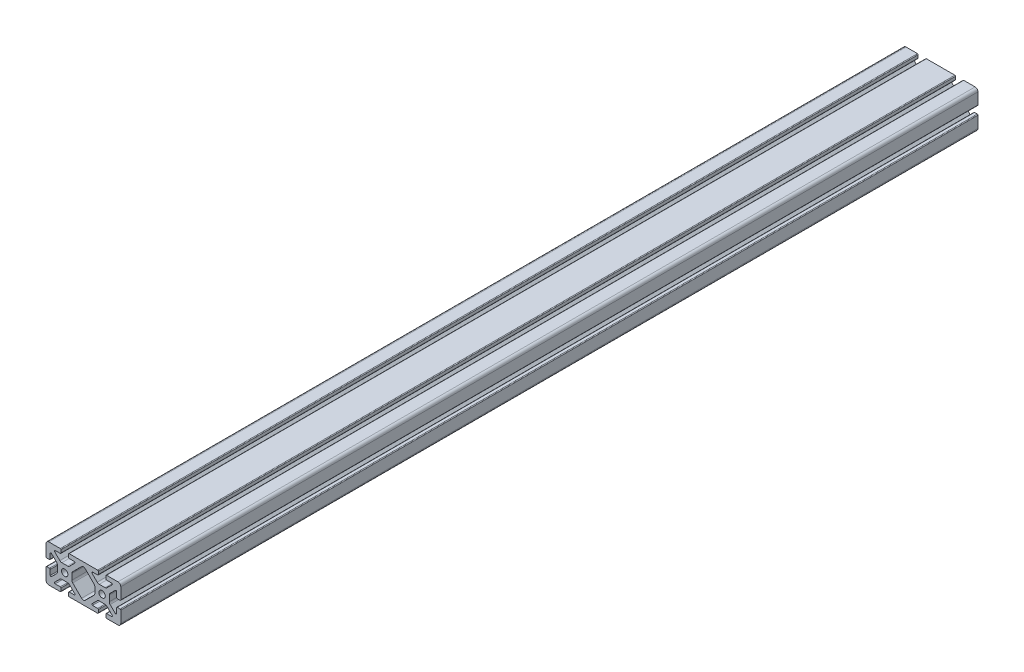
from build123d import *

# Parameters (mm, degrees)
SKETCH1_R           = 3.4036
BOSS_EXTRUDE1_DEPTH = 457.2


with BuildPart() as part:
    # Sketch1 → Boss-Extrude1 (new body, symmetric)
    with BuildSketch(Plane.XY):
        with BuildLine():
            Line((-39.878, 16.891), (-39.878, 4.7625))
            ThreePointArc((-39.878, 4.7625), (-39.654815367, 4.223684633), (-39.116, 4.0005))
            Line((-39.116, 4.0005), (-36.1442, 4.0005))
            ThreePointArc((-36.1442, 4.0005), (-35.605384633, 4.223684633), (-35.3822, 4.7625))
            Line((-35.3822, 4.7625), (-35.3822, 10.2235))
            ThreePointArc((-35.3822, 10.2235), (-34.911804775, 10.927496204), (-34.081384633, 10.762315367))
            Line((-34.081384633, 10.762315367), (-28.513059555, 5.19399029))
            ThreePointArc((-28.513059555, 5.19399029), (-27.863348265, 4.221628629), (-27.6352, 3.074649845))
            Line((-27.6352, 3.074649845), (-27.6352, -3.074649845))
            ThreePointArc((-27.6352, -3.074649845), (-27.863348265, -4.221628629), (-28.513059555, -5.19399029))
            Line((-28.513059555, -5.19399029), (-34.081384633, -10.762315367))
            ThreePointArc((-34.081384633, -10.762315367), (-34.911804775, -10.927496204), (-35.3822, -10.2235))
            Line((-35.3822, -10.2235), (-35.3822, -4.7625))
            ThreePointArc((-35.3822, -4.7625), (-35.605384633, -4.223684633), (-36.1442, -4.0005))
            Line((-36.1442, -4.0005), (-39.116, -4.0005))
            ThreePointArc((-39.116, -4.0005), (-39.654815367, -4.223684633), (-39.878, -4.7625))
            Line((-39.878, -4.7625), (-39.878, -16.891))
            ThreePointArc((-39.878, -16.891), (-38.985261469, -19.046261469), (-36.83, -19.939))
            Line((-36.83, -19.939), (-24.7015, -19.939))
            ThreePointArc((-24.7015, -19.939), (-24.162684633, -19.715815367), (-23.9395, -19.177))
            Line((-23.9395, -19.177), (-23.9395, -16.2052))
            ThreePointArc((-23.9395, -16.2052), (-24.162684633, -15.666384633), (-24.7015, -15.4432))
            Line((-24.7015, -15.4432), (-30.1625, -15.4432))
            ThreePointArc((-30.1625, -15.4432), (-30.866496204, -14.972804775), (-30.701315367, -14.142384633))
            Line((-30.701315367, -14.142384633), (-25.13299029, -8.574059555))
            ThreePointArc((-25.13299029, -8.574059555), (-24.160628629, -7.924348265), (-23.013649845, -7.6962))
            Line((-23.013649845, -7.6962), (-16.864350155, -7.6962))
            ThreePointArc((-16.864350155, -7.6962), (-15.717371371, -7.924348265), (-14.74500971, -8.574059555))
            Line((-14.74500971, -8.574059555), (-9.176684633, -14.142384633))
            ThreePointArc((-9.176684633, -14.142384633), (-9.011503796, -14.972804775), (-9.7155, -15.4432))
            Line((-9.7155, -15.4432), (-15.1765, -15.4432))
            ThreePointArc((-15.1765, -15.4432), (-15.715315367, -15.666384633), (-15.9385, -16.2052))
            Line((-15.9385, -16.2052), (-15.9385, -19.177))
            ThreePointArc((-15.9385, -19.177), (-15.715315367, -19.715815367), (-15.1765, -19.939))
            Line((-15.1765, -19.939), (15.1765, -19.939))
            ThreePointArc((15.1765, -19.939), (15.715315367, -19.715815367), (15.9385, -19.177))
            Line((15.9385, -19.177), (15.9385, -16.2052))
            ThreePointArc((15.9385, -16.2052), (15.715315367, -15.666384633), (15.1765, -15.4432))
            Line((15.1765, -15.4432), (9.7155, -15.4432))
            ThreePointArc((9.7155, -15.4432), (9.011503796, -14.972804775), (9.176684633, -14.142384633))
            Line((9.176684633, -14.142384633), (14.74500971, -8.574059555))
            ThreePointArc((14.74500971, -8.574059555), (15.717371371, -7.924348265), (16.864350155, -7.6962))
            Line((16.864350155, -7.6962), (23.013649845, -7.6962))
            ThreePointArc((23.013649845, -7.6962), (24.160628629, -7.924348265), (25.13299029, -8.574059555))
            Line((25.13299029, -8.574059555), (30.701315367, -14.142384633))
            ThreePointArc((30.701315367, -14.142384633), (30.866496204, -14.972804775), (30.1625, -15.4432))
            Line((30.1625, -15.4432), (24.7015, -15.4432))
            ThreePointArc((24.7015, -15.4432), (24.162684633, -15.666384633), (23.9395, -16.2052))
            Line((23.9395, -16.2052), (23.9395, -19.177))
            ThreePointArc((23.9395, -19.177), (24.162684633, -19.715815367), (24.7015, -19.939))
            Line((24.7015, -19.939), (36.83, -19.939))
            ThreePointArc((36.83, -19.939), (38.985261469, -19.046261469), (39.878, -16.891))
            Line((39.878, -16.891), (39.878, -4.7625))
            ThreePointArc((39.878, -4.7625), (39.654815367, -4.223684633), (39.116, -4.0005))
            Line((39.116, -4.0005), (36.1442, -4.0005))
            ThreePointArc((36.1442, -4.0005), (35.605384633, -4.223684633), (35.3822, -4.7625))
            Line((35.3822, -4.7625), (35.3822, -10.2235))
            ThreePointArc((35.3822, -10.2235), (34.911804775, -10.927496204), (34.081384633, -10.762315367))
            Line((34.081384633, -10.762315367), (28.513059555, -5.19399029))
            ThreePointArc((28.513059555, -5.19399029), (27.863348265, -4.221628629), (27.6352, -3.074649845))
            Line((27.6352, -3.074649845), (27.6352, 3.074649845))
            ThreePointArc((27.6352, 3.074649845), (27.863348265, 4.221628629), (28.513059555, 5.19399029))
            Line((28.513059555, 5.19399029), (34.081384633, 10.762315367))
            ThreePointArc((34.081384633, 10.762315367), (34.911804775, 10.927496204), (35.3822, 10.2235))
            Line((35.3822, 10.2235), (35.3822, 4.7625))
            ThreePointArc((35.3822, 4.7625), (35.605384633, 4.223684633), (36.1442, 4.0005))
            Line((36.1442, 4.0005), (39.116, 4.0005))
            ThreePointArc((39.116, 4.0005), (39.654815367, 4.223684633), (39.878, 4.7625))
            Line((39.878, 4.7625), (39.878, 16.891))
            ThreePointArc((39.878, 16.891), (38.985261469, 19.046261469), (36.83, 19.939))
            Line((36.83, 19.939), (24.7015, 19.939))
            ThreePointArc((24.7015, 19.939), (24.162684633, 19.715815367), (23.9395, 19.177))
            Line((23.9395, 19.177), (23.9395, 16.2052))
            ThreePointArc((23.9395, 16.2052), (24.162684633, 15.666384633), (24.7015, 15.4432))
            Line((24.7015, 15.4432), (30.1625, 15.4432))
            ThreePointArc((30.1625, 15.4432), (30.866496204, 14.972804775), (30.701315367, 14.142384633))
            Line((30.701315367, 14.142384633), (25.13299029, 8.574059555))
            ThreePointArc((25.13299029, 8.574059555), (24.160628629, 7.924348265), (23.013649845, 7.6962))
            Line((23.013649845, 7.6962), (16.864350155, 7.6962))
            ThreePointArc((16.864350155, 7.6962), (15.717371371, 7.924348265), (14.74500971, 8.574059555))
            Line((14.74500971, 8.574059555), (9.176684633, 14.142384633))
            ThreePointArc((9.176684633, 14.142384633), (9.011503796, 14.972804775), (9.7155, 15.4432))
            Line((9.7155, 15.4432), (15.1765, 15.4432))
            ThreePointArc((15.1765, 15.4432), (15.715315367, 15.666384633), (15.9385, 16.2052))
            Line((15.9385, 16.2052), (15.9385, 19.177))
            ThreePointArc((15.9385, 19.177), (15.715315367, 19.715815367), (15.1765, 19.939))
            Line((15.1765, 19.939), (-15.1765, 19.939))
            ThreePointArc((-15.1765, 19.939), (-15.715315367, 19.715815367), (-15.9385, 19.177))
            Line((-15.9385, 19.177), (-15.9385, 16.2052))
            ThreePointArc((-15.9385, 16.2052), (-15.715315367, 15.666384633), (-15.1765, 15.4432))
            Line((-15.1765, 15.4432), (-9.7155, 15.4432))
            ThreePointArc((-9.7155, 15.4432), (-9.011503796, 14.972804775), (-9.176684633, 14.142384633))
            Line((-9.176684633, 14.142384633), (-14.74500971, 8.574059555))
            ThreePointArc((-14.74500971, 8.574059555), (-15.717371371, 7.924348265), (-16.864350155, 7.6962))
            Line((-16.864350155, 7.6962), (-23.013649845, 7.6962))
            ThreePointArc((-23.013649845, 7.6962), (-24.160628629, 7.924348265), (-25.13299029, 8.574059555))
            Line((-25.13299029, 8.574059555), (-30.701315367, 14.142384633))
            ThreePointArc((-30.701315367, 14.142384633), (-30.866496204, 14.972804775), (-30.1625, 15.4432))
            Line((-30.1625, 15.4432), (-24.7015, 15.4432))
            ThreePointArc((-24.7015, 15.4432), (-24.162684633, 15.666384633), (-23.9395, 16.2052))
            Line((-23.9395, 16.2052), (-23.9395, 19.177))
            ThreePointArc((-23.9395, 19.177), (-24.162684633, 19.715815367), (-24.7015, 19.939))
            Line((-24.7015, 19.939), (-36.83, 19.939))
            ThreePointArc((-36.83, 19.939), (-38.985261469, 19.046261469), (-39.878, 16.891))
        make_face()
        with Locations((-19.939, 0)):
            Circle(SKETCH1_R, mode=Mode.SUBTRACT)
        with Locations((19.939, 0)):
            Circle(SKETCH1_R, mode=Mode.SUBTRACT)
        with BuildLine():
            Line((-12.2428, 3.074649845), (-12.2428, -3.074649845))
            ThreePointArc((-12.2428, -3.074649845), (-12.014651735, -4.221628629), (-11.364940445, -5.19399029))
            Line((-11.364940445, -5.19399029), (-1.904671503, -14.654259232))
            ThreePointArc((-1.904671503, -14.654259232), (0, -15.4432), (1.904671503, -14.654259232))
            Line((1.904671503, -14.654259232), (11.364940445, -5.19399029))
            ThreePointArc((11.364940445, -5.19399029), (12.014651735, -4.221628629), (12.2428, -3.074649845))
            Line((12.2428, -3.074649845), (12.2428, 3.074649845))
            ThreePointArc((12.2428, 3.074649845), (12.014651735, 4.221628629), (11.364940445, 5.19399029))
            Line((11.364940445, 5.19399029), (1.904671503, 14.654259232))
            ThreePointArc((1.904671503, 14.654259232), (0, 15.4432), (-1.904671503, 14.654259232))
            Line((-1.904671503, 14.654259232), (-11.364940445, 5.19399029))
            ThreePointArc((-11.364940445, 5.19399029), (-12.014651735, 4.221628629), (-12.2428, 3.074649845))
        make_face(mode=Mode.SUBTRACT)
    extrude(amount=BOSS_EXTRUDE1_DEPTH, both=True)


solid = part.part
